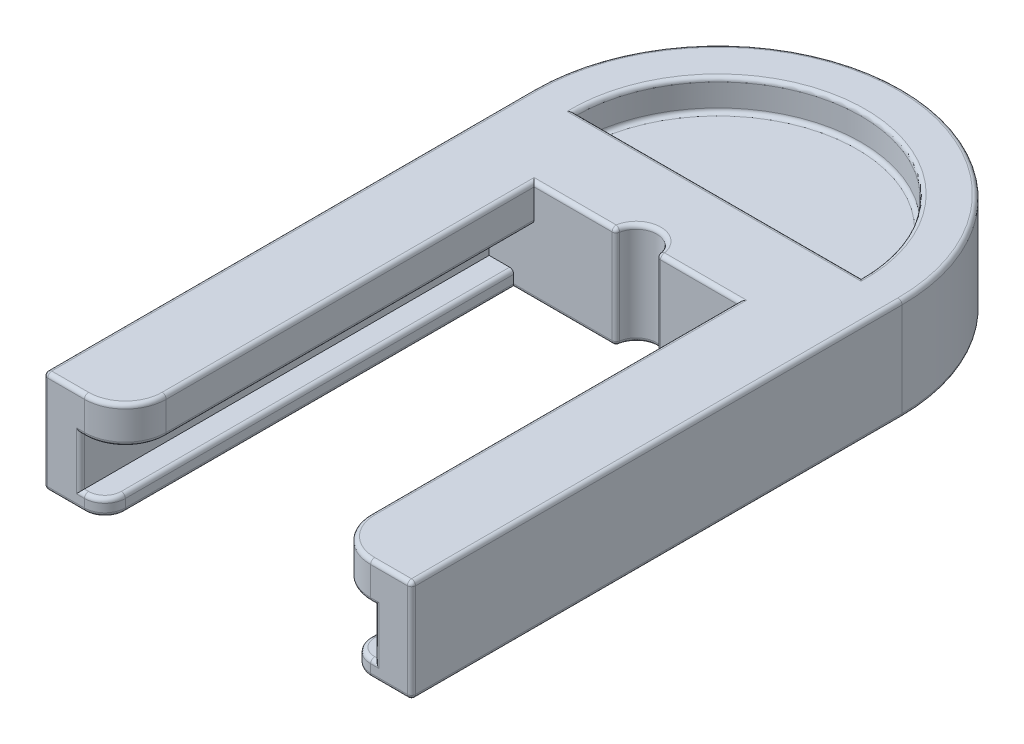
from build123d import *

# Parameters (mm, degrees)
BOSS_EXTRUDE1_DEPTH      = 50
BOSS_EXTRUDE1_2_DEPTH    = 50
SKETCH2_W                = 45
SKETCH2_H                = 12.5
BOSS_EXTRUDE2_DEPTH      = 10
BOSS_EXTRUDE3_START      = -6.25
BOSS_EXTRUDE3_DEPTH      = 12.5
BOSS_EXTRUDE4_DEPTH      = 2.5
BOSS_EXTRUDE4_DEPTH_BACK = 2.5
FILLET1_R                = 5
FILLET2_R                = 2.5
SKETCH5_R                = 2.5
CUT_EXTRUDE1_DEPTH       = 13.5
FILLET3_R                = 0.5


with BuildPart() as part:
    # Sketch1 → Boss-Extrude1 (new body)
    with BuildSketch(Plane.XY):
        Polygon((-12.5, 7.5), (-22.5, 7.5), (-22.5, -5), (-15, -5), (-15, -3), (-18, -3), (-18, 3), (-12.5, 3), align=None)
    extrude(amount=BOSS_EXTRUDE1_DEPTH)



with BuildPart() as body_2:
    # Sketch1 → Boss-Extrude1 2 (new body)
    with BuildSketch(Plane.XY):
        Polygon((22.5, 7.5), (22.5, -5), (15, -5), (15, -3), (18, -3), (18, 3), (12.5, 3), (12.5, 7.5), align=None)
    extrude(amount=BOSS_EXTRUDE1_2_DEPTH)


with BuildPart() as part_1:
    add(part.part)

    add(body_2.part)  # Boss-Extrude2 merges body 2
    # Sketch2 → Boss-Extrude2 (add)
    with BuildSketch(Plane.XY):
        with Locations((0, 1.25)):
            Rectangle(SKETCH2_W, SKETCH2_H)
    extrude(amount=-BOSS_EXTRUDE2_DEPTH)

    # Sketch3 → Boss-Extrude3 (add)
    with BuildSketch(Plane.XZ.offset(-1.25).offset(BOSS_EXTRUDE3_START)):
        with BuildLine():
            Line((-22.5, -10), (-17.5, -10))
            ThreePointArc((-17.5, -10), (0, -27.5), (17.5, -10))
            Line((17.5, -10), (22.5, -10))
            ThreePointArc((22.5, -10), (0, -32.5), (-22.5, -10))
        make_face()
    extrude(amount=BOSS_EXTRUDE3_DEPTH)

    # Sketch4 → Boss-Extrude4 (add, two sides)
    with BuildSketch(Plane(origin=(0, 1.25, 0), x_dir=(1, 0, 0), z_dir=(0, 1, 0))) as boss_extrude4_sk:
        with BuildLine():
            Line((-17.5, 10), (17.5, 10))
            ThreePointArc((17.5, 10), (0, 27.5), (-17.5, 10))
        make_face()
    extrude(amount=BOSS_EXTRUDE4_DEPTH)
    extrude(boss_extrude4_sk.sketch, amount=-BOSS_EXTRUDE4_DEPTH_BACK)

    # Fillet1
    fillet1_edges = [part_1.edges().sort_by_distance(p)[0] for p in [
        (12.5, 5.25, 50),
        (-12.5, 5.25, 50),
    ]]
    fillet(fillet1_edges, radius=FILLET1_R)

    # Fillet2
    fillet2_edges = [part_1.edges().sort_by_distance(p)[0] for p in [
        (-15, -4, 50),
        (15, -4, 50),
    ]]
    fillet(fillet2_edges, radius=FILLET2_R)

    # Sketch5 → Cut-Extrude1 (cut, through all)
    with BuildSketch(Plane(origin=(0, 7.5, 0), x_dir=(1, 0, 0), z_dir=(0, 1, 0))):
        Circle(SKETCH5_R)
    extrude(amount=-CUT_EXTRUDE1_DEPTH, mode=Mode.SUBTRACT)

    # Fillet3
    fillet3_edges = [part_1.edges().sort_by_distance(p)[0] for p in [
        (8.75, -5, 0),
        (-7.5, 7.5, 0),
        (2.5, 1.25, 0),
        (-2.5, 1.25, 0),
        (0, -5, -2.5),
        (0, 7.5, -2.5),
        (-22.5, 1.25, 50),
        (-22.5, -5, 20),
        (-22.5, 7.5, 20),
        (-20, -5, 50),
        (-8.75, -5, 0),
        (22.5, 7.5, 20),
        (22.5, -5, 20),
        (-18, 0, 50),
        (-17.75, 3, 50),
        (7.5, 7.5, 0),
        (20, 7.5, 50),
        (18, 0, 50),
        (17.75, -3, 50),
        (22.5, 1.25, 50),
        (0, 7.5, -10),
        (0, -5, -10),
        (0, -5, -27.5),
        (0, -5, -32.5),
        (0, 7.5, -32.5),
        (0, 7.5, -27.5),
        (0, -1.25, -27.5),
        (0, -1.25, -10),
        (0, 3.75, -27.5),
        (0, 3.75, -10),
        (17.75, 3, 50),
        (12.5, 3, 22.5),
        (13.964466094, 3, 48.535533906),
        (12.5, 7.5, 22.5),
        (-12.5, 7.5, 22.5),
        (-20, 7.5, 50),
        (-13.964466094, 7.5, 48.535533906),
        (13.964466094, 7.5, 48.535533906),
        (-12.5, 3, 22.5),
        (-13.964466094, 3, 48.535533906),
        (20, -5, 50),
        (15, -5, 23.75),
        (-15, -5, 23.75),
        (-15.732233047, -5, 49.267766953),
        (15.732233047, -5, 49.267766953),
        (15, -3, 23.75),
        (15.732233047, -3, 49.267766953),
        (-17.75, -3, 50),
        (-15, -3, 23.75),
        (-15.732233047, -3, 49.267766953),
    ]]
    fillet(fillet3_edges, radius=FILLET3_R)


solid = part_1.part
